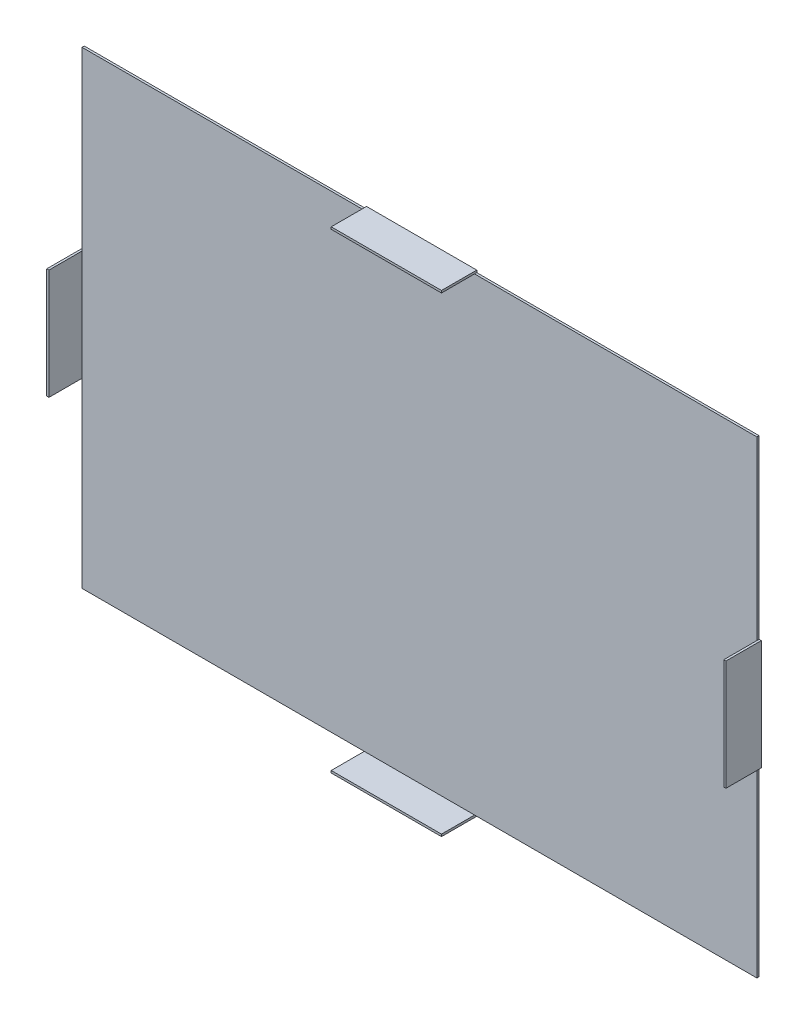
from build123d import *

# Parameters (mm, degrees)
SKETCH_1_W          = 612
SKETCH_1_H          = 425
EXTRUDE_1_DEPTH     = 2
SKETCH_2_W          = 100
SKETCH_2_H          = 32
EXTRUDE_2_DEPTH     = 2
SKETCH_3_W          = 32
SKETCH_3_H          = 100
EXTRUDE_3_DEPTH     = 2
SKETCH_4_W          = 100
SKETCH_4_H          = 32
EXTRUDE_4_DEPTH     = 2
SKETCH_5_W          = 32
SKETCH_5_H          = 100
EXTRUDE_5_DEPTH     = 2
SKETCH_6_W          = 30
SKETCH_6_H          = 30
SKETCH_6_W_2        = 26
SKETCH_6_H_2        = 26
EXTRUDE_6_DEPTH     = 30
SKETCH_7_W          = 30
SKETCH_7_H          = 30
SKETCH_7_W_2        = 26
SKETCH_7_H_2        = 26
EXTRUDE_7_DEPTH     = 30
SKETCH_8_R          = 2
CUT_EXTRUDE_1_DEPTH = 388.5
SKETCH_9_R          = 2
CUT_EXTRUDE_2_DEPTH = 572.25


with BuildPart() as part:
    # 草圖1 → 填料-伸長1 (new body)
    with BuildSketch(Plane.XY):
        with Locations((4.21177851, 12.129893238)):
            Rectangle(SKETCH_1_W, SKETCH_1_H)
    extrude(amount=EXTRUDE_1_DEPTH)

    # 草圖2 → 填料-伸長2 (add)
    with BuildSketch(Plane.XZ.offset(200.370106762)):
        with Locations((4.21177851, 16)):
            Rectangle(SKETCH_2_W, SKETCH_2_H)
    extrude(amount=EXTRUDE_2_DEPTH)

    # 草圖3 → 填料-伸長3 (add)
    with BuildSketch(Plane.ZY.offset(301.78822149)):
        with Locations((16, 14.629893238)):
            Rectangle(SKETCH_3_W, SKETCH_3_H)
    extrude(amount=EXTRUDE_3_DEPTH)

    # 草圖4 → 填料-伸長4 (add)
    with BuildSketch(Plane(origin=(0, 224.629893238, 0), x_dir=(1, 0, 0), z_dir=(0, 1, 0))):
        with Locations((4.21177851, -16)):
            Rectangle(SKETCH_4_W, SKETCH_4_H)
    extrude(amount=EXTRUDE_4_DEPTH)

    # 草圖5 → 填料-伸長5 (add)
    with BuildSketch(Plane(origin=(310.21177851, 0, 0), x_dir=(0, 0, -1), z_dir=(1, 0, 0))):
        with Locations((-16, 14.629893238)):
            Rectangle(SKETCH_5_W, SKETCH_5_H)
    extrude(amount=EXTRUDE_5_DEPTH)

    # 草圖6 → 填料-伸長6 (add)
    with BuildSketch(Plane(origin=(0, 0, 0), x_dir=(-1, 0, 0), z_dir=(0, 0, -1))):
        with Locations((-252.46177851, 12.129893238)):
            Rectangle(SKETCH_6_W, SKETCH_6_H)
        with Locations((-252.46177851, 12.129893238)):
            Rectangle(SKETCH_6_W_2, SKETCH_6_H_2, mode=Mode.SUBTRACT)
        with Locations((244.03822149, 12.129893238)):
            Rectangle(SKETCH_6_W, SKETCH_6_H)
        with Locations((244.03822149, 12.129893238)):
            Rectangle(SKETCH_6_W_2, SKETCH_6_H_2, mode=Mode.SUBTRACT)
    extrude(amount=EXTRUDE_6_DEPTH)

    # 草圖7 → 填料-伸長7 (add)
    with BuildSketch(Plane(origin=(0, 0, 0), x_dir=(-1, 0, 0), z_dir=(0, 0, -1))):
        with Locations((-4.21177851, -145.870106762)):
            Rectangle(SKETCH_7_W, SKETCH_7_H)
        with Locations((-4.21177851, -145.870106762)):
            Rectangle(SKETCH_7_W_2, SKETCH_7_H_2, mode=Mode.SUBTRACT)
        with Locations((-4.21177851, 170.129893238)):
            Rectangle(SKETCH_7_W, SKETCH_7_H)
        with Locations((-4.21177851, 170.129893238)):
            Rectangle(SKETCH_7_W_2, SKETCH_7_H_2, mode=Mode.SUBTRACT)
    extrude(amount=EXTRUDE_7_DEPTH)

    # 草圖8 → 除料-伸長1 (cut, through all)
    with BuildSketch(Plane(origin=(0, 185.129893238, 0), x_dir=(1, 0, 0), z_dir=(0, 1, 0))):
        with Locations((4.21177851, 15)):
            Circle(SKETCH_8_R)
    extrude(amount=-CUT_EXTRUDE_1_DEPTH, mode=Mode.SUBTRACT)

    # 草圖9 → 除料-伸長2 (cut, through all)
    with BuildSketch(Plane.ZY.offset(259.03822149)):
        with Locations((-15, 12.129893238)):
            Circle(SKETCH_9_R)
    extrude(amount=-CUT_EXTRUDE_2_DEPTH, mode=Mode.SUBTRACT)


solid = part.part
